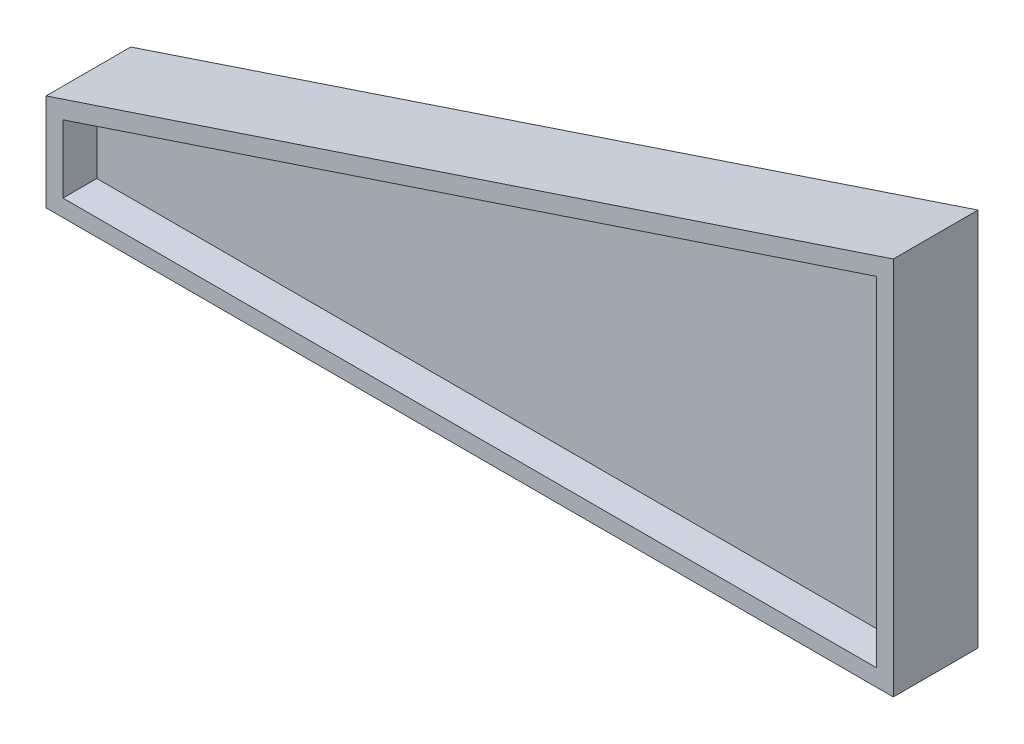
from build123d import *

# Parameters (mm, degrees)
BOSS_EXTRUDE1_DEPTH      = 12.7
BOSS_EXTRUDE2_DEPTH      = 25.4
BOSS_EXTRUDE2_DEPTH_BACK = 38.1


with BuildPart() as part:
    # Sketch1 → Boss-Extrude1 (new body)
    with BuildSketch(Plane.XY):
        Polygon((0, 0), (0, 254), (-609.6, 50.8), (-609.6, 0), align=None)
    extrude(amount=BOSS_EXTRUDE1_DEPTH)

    # Sketch2 → Boss-Extrude2 (add, two sides)
    with BuildSketch(Plane.XY.offset(12.7)) as boss_extrude2_sk:
        Polygon((12.7, -12.7), (12.7, 271.620308761), (-622.3, 59.953642095), (-622.3, -12.7), align=None)
        Polygon((0, 254), (-609.6, 50.8), (-609.6, 0), (0, 0), align=None, mode=Mode.SUBTRACT)
    extrude(amount=BOSS_EXTRUDE2_DEPTH)
    extrude(boss_extrude2_sk.sketch, amount=-BOSS_EXTRUDE2_DEPTH_BACK)


solid = part.part
